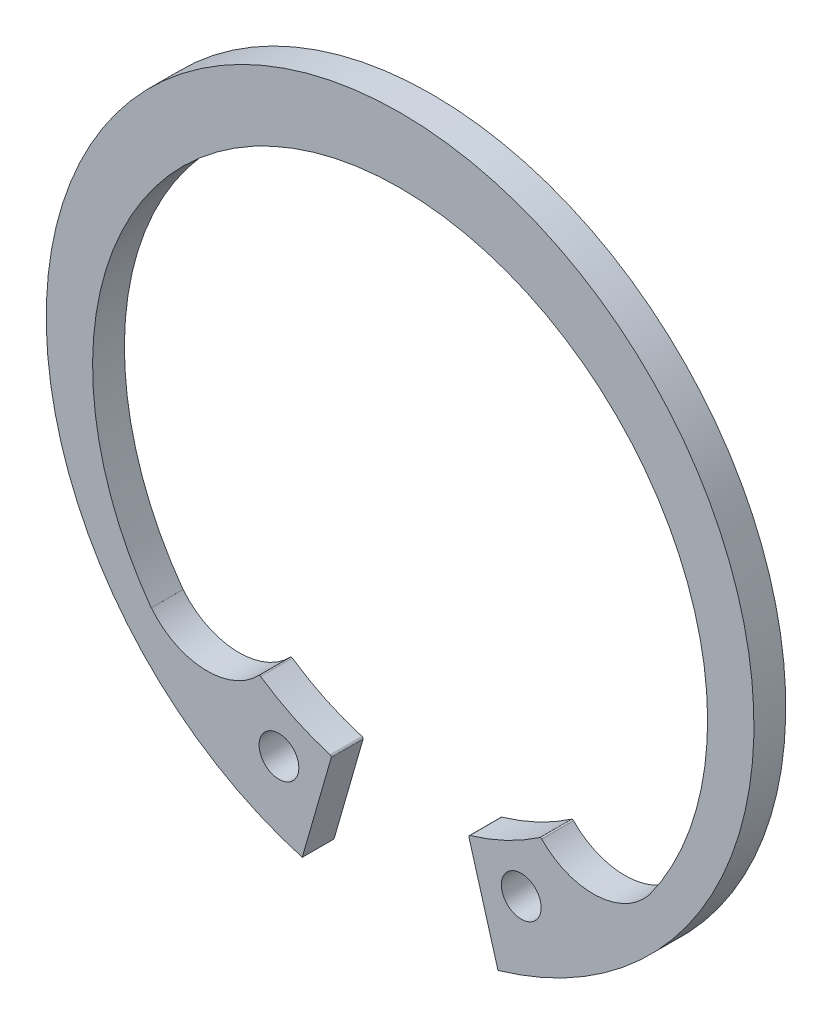
from build123d import *

# Parameters (mm, degrees)
BODYSKE_R    = 1.25
BODY_DEPTH   = 2
MODLUGSKE_R  = 1.25
MODLUG_DEPTH = 2


with BuildPart() as part:
    # BodySke → Body (new body)
    with BuildSketch(Plane.XY):
        with BuildLine():
            Line((6.15473831, -21.381807602), (4.998669473, -17.365578122))
            ThreePointArc((4.998669473, -17.365578122), (6.301661395, -14.225456519), (9.652536987, -14.799725088))
            ThreePointArc((9.652536987, -14.799725088), (11.602164826, -15.711310789), (13.605169738, -14.923904589))
            ThreePointArc((13.605169738, -14.923904589), (0, 18.15), (-13.605169738, -14.923904589))
            ThreePointArc((-13.605169738, -14.923904589), (-11.602164826, -15.711310789), (-9.652536987, -14.799725088))
            ThreePointArc((-9.652536987, -14.799725088), (-6.301661395, -14.225456519), (-4.998669473, -17.365578122))
            Line((-4.998669473, -17.365578122), (-6.15473831, -21.381807602))
            ThreePointArc((-6.15473831, -21.381807602), (0, 22.25), (6.15473831, -21.381807602))
        make_face()
        with Locations((7.617340292, -16.611795564)):
            Circle(BODYSKE_R, mode=Mode.SUBTRACT)
        with Locations((-7.617340292, -16.611795564)):
            Circle(BODYSKE_R, mode=Mode.SUBTRACT)
    extrude(amount=-BODY_DEPTH)

    # ModLugSke → ModLug (add, through all)
    with BuildSketch(Plane.XY):
        with BuildLine():
            Line((6.15473831, -21.381807602), (4.328974749, -15.039031805))
            ThreePointArc((4.328974749, -15.039031805), (4.337407237, -14.963258149), (4.396797536, -14.915450762))
            ThreePointArc((4.396797536, -14.915450762), (6.665405802, -14.049016531), (8.771452297, -12.839942547))
            ThreePointArc((8.771452297, -12.839942547), (8.837981797, -12.823028062), (8.899741793, -12.852994325))
            ThreePointArc((8.899741793, -12.852994325), (12.341754083, -14.219037165), (15.642102603, -12.539388009))
            Line((15.642102603, -12.539388009), (17.360405349, -13.916854031))
            ThreePointArc((17.360405349, -13.916854031), (12.335796621, -18.517306006), (6.15473831, -21.381807602))
        make_face()
        with Locations((7.617340292, -16.611795564)):
            Circle(MODLUGSKE_R, mode=Mode.SUBTRACT)
        with BuildLine():
            Line((-6.15473831, -21.381807602), (-4.328974749, -15.039031805))
            ThreePointArc((-4.328974749, -15.039031805), (-4.337407237, -14.963258149), (-4.396797536, -14.915450762))
            ThreePointArc((-4.396797536, -14.915450762), (-6.665405802, -14.049016531), (-8.771452297, -12.839942547))
            ThreePointArc((-8.771452297, -12.839942547), (-8.837981797, -12.823028062), (-8.899741793, -12.852994325))
            ThreePointArc((-8.899741793, -12.852994325), (-12.341754083, -14.219037165), (-15.642102603, -12.539388009))
            Line((-15.642102603, -12.539388009), (-17.360405349, -13.916854031))
            ThreePointArc((-17.360405349, -13.916854031), (-12.335796621, -18.517306006), (-6.15473831, -21.381807602))
        make_face()
        with Locations((-7.617340292, -16.611795564)):
            Circle(MODLUGSKE_R, mode=Mode.SUBTRACT)
    extrude(amount=-MODLUG_DEPTH)


solid = part.part
